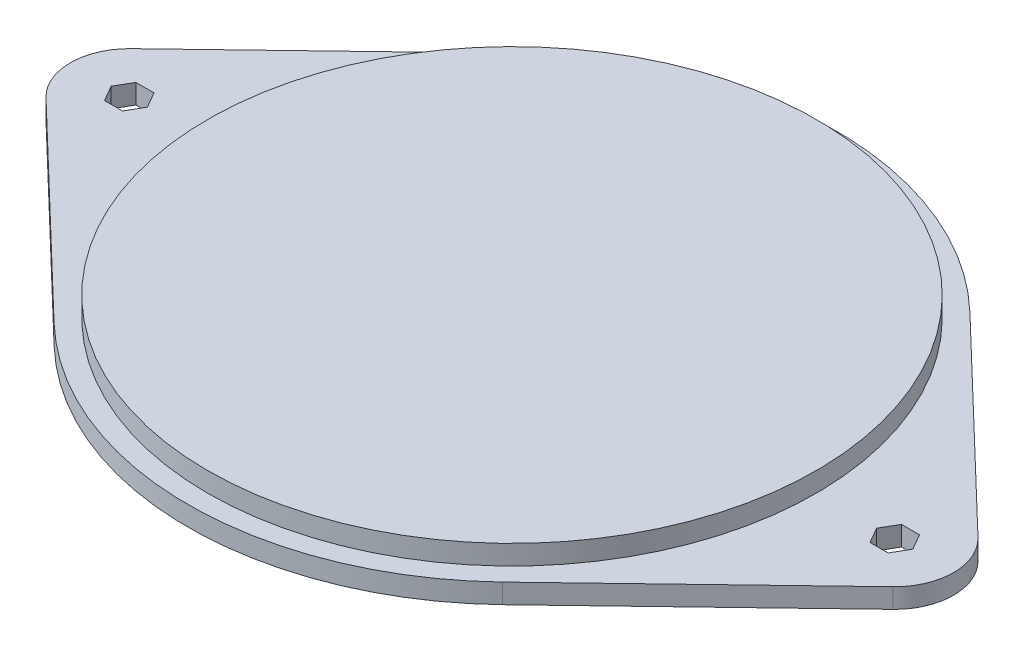
from build123d import *

# Parameters (mm, degrees)
BOSS_EXTRUDE1_DEPTH = 5
SKETCH2_R           = 77.5
BOSS_EXTRUDE2_DEPTH = 5
CUT_EXTRUDE1_DEPTH  = 6


with BuildPart() as part:
    # Sketch1 → Boss-Extrude1 (new body)
    with BuildSketch(Plane(origin=(0, 0, 0), x_dir=(1, 0, 0), z_dir=(0, 1, 0))):
        with BuildLine():
            Line((107.884615385, 10.824036369), (57.115384615, 59.532200029))
            ThreePointArc((57.115384615, 59.532200029), (0, 82.5), (-57.115384615, 59.532200029))
            Line((-57.115384615, 59.532200029), (-107.884615385, 10.824036369))
            ThreePointArc((-107.884615385, 10.824036369), (-112.5, 0), (-107.884615385, -10.824036369))
            Line((-107.884615385, -10.824036369), (-57.115384615, -59.532200029))
            ThreePointArc((-57.115384615, -59.532200029), (0, -82.5), (57.115384615, -59.532200029))
            Line((57.115384615, -59.532200029), (107.884615385, -10.824036369))
            ThreePointArc((107.884615385, -10.824036369), (112.5, 0), (107.884615385, 10.824036369))
        make_face()
    extrude(amount=BOSS_EXTRUDE1_DEPTH)

    # Sketch2 → Boss-Extrude2 (add)
    with BuildSketch(Plane(origin=(0, 5, 0), x_dir=(1, 0, 0), z_dir=(0, 1, 0))):
        Circle(SKETCH2_R)
    extrude(amount=BOSS_EXTRUDE2_DEPTH)

    # Sketch3 → Cut-Extrude1 (cut, through all)
    with BuildSketch(Plane(origin=(0, 5, 0), x_dir=(1, 0, 0), z_dir=(0, 1, 0))):
        Polygon((-95.190598923, 4), (-99.809401077, 4), (-102.118802154, 0), (-99.809401077, -4), (-95.190598923, -4), (-92.881197846, 0), align=None)
        Polygon((99.809401077, 4), (95.190598923, 4), (92.881197846, 0), (95.190598923, -4), (99.809401077, -4), (102.118802154, 0), align=None)
    extrude(amount=-CUT_EXTRUDE1_DEPTH, mode=Mode.SUBTRACT)


solid = part.part
